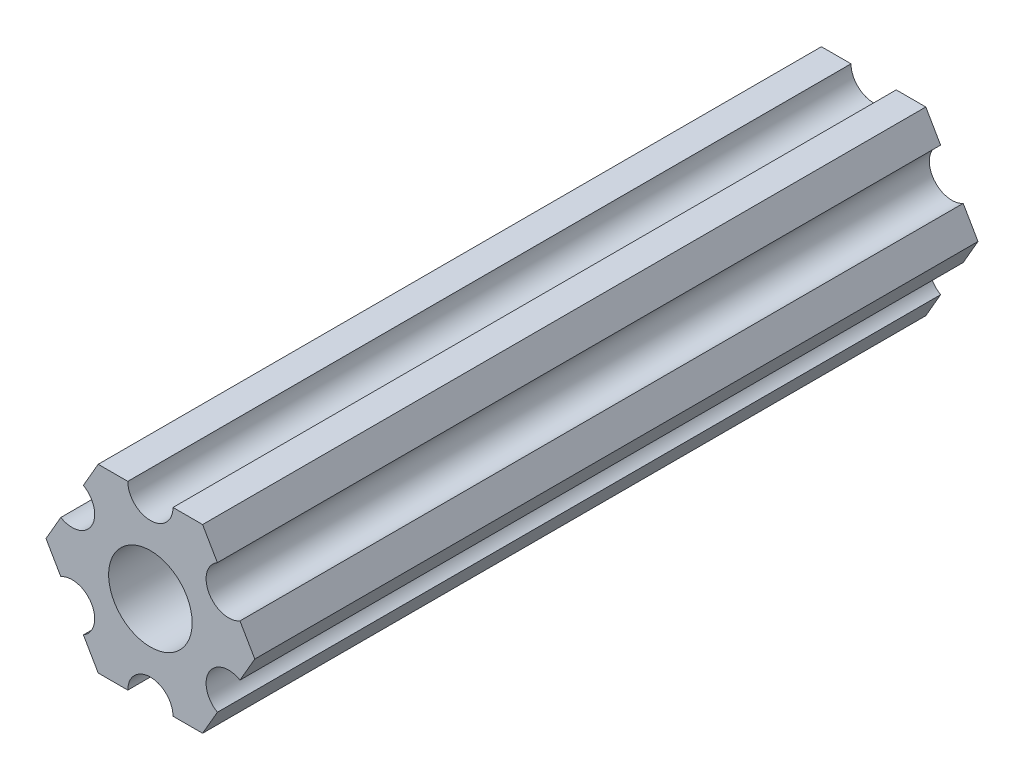
from build123d import *

# Parameters (mm, degrees)
SKETCH1_R           = 2.9337
BOSS_EXTRUDE2_DEPTH = 50.8


with BuildPart() as part:
    # Sketch1 → Boss-Extrude2 (new body)
    with BuildSketch(Plane(origin=(0, 0, 0), x_dir=(-1, 0, 0), z_dir=(0, 0, -1))):
        with BuildLine():
            Line((-4.70551159, -4.549815043), (-3.666174521, -6.349999904))
            Line((-3.666174521, -6.349999904), (-1.587500385, -6.349999904))
            ThreePointArc((-1.587500385, -6.349999904), (-3.85e-07, -4.762499904), (1.587499615, -6.349999904))
            Line((1.587499615, -6.349999904), (3.666173825, -6.349999904))
            Line((3.666173825, -6.349999904), (4.705510929, -4.549815232))
            ThreePointArc((4.705510929, -4.549815232), (4.124445601, -2.381249904), (6.293010929, -1.800184575))
            Line((6.293010929, -1.800184575), (7.332348034, 9.6e-08))
            Line((7.332348034, 9.6e-08), (6.293011178, 1.800184715))
            ThreePointArc((6.293011178, 1.800184715), (4.124445902, 2.381250241), (4.705511428, 4.549815516))
            Line((4.705511428, 4.549815516), (3.666174521, 6.350000222))
            Line((3.666174521, 6.350000222), (1.587500385, 6.350000222))
            ThreePointArc((1.587500385, 6.350000222), (3.85e-07, 4.762500222), (-1.587499615, 6.350000222))
            Line((-1.587499615, 6.350000222), (-3.666173825, 6.350000222))
            Line((-3.666173825, 6.350000222), (-4.705511038, 4.549815614))
            ThreePointArc((-4.705511038, 4.549815614), (-4.124445841, 2.38125025), (-6.293011205, 1.800185053))
            Line((-6.293011205, 1.800185053), (-7.332348419, 4.44e-07))
            Line((-7.332348419, 4.44e-07), (-6.293011423, -1.80018429))
            ThreePointArc((-6.293011423, -1.80018429), (-4.12444613, -2.38124975), (-4.70551159, -4.549815043))
        make_face()
        Circle(SKETCH1_R, mode=Mode.SUBTRACT)
    extrude(amount=BOSS_EXTRUDE2_DEPTH)


solid = part.part
